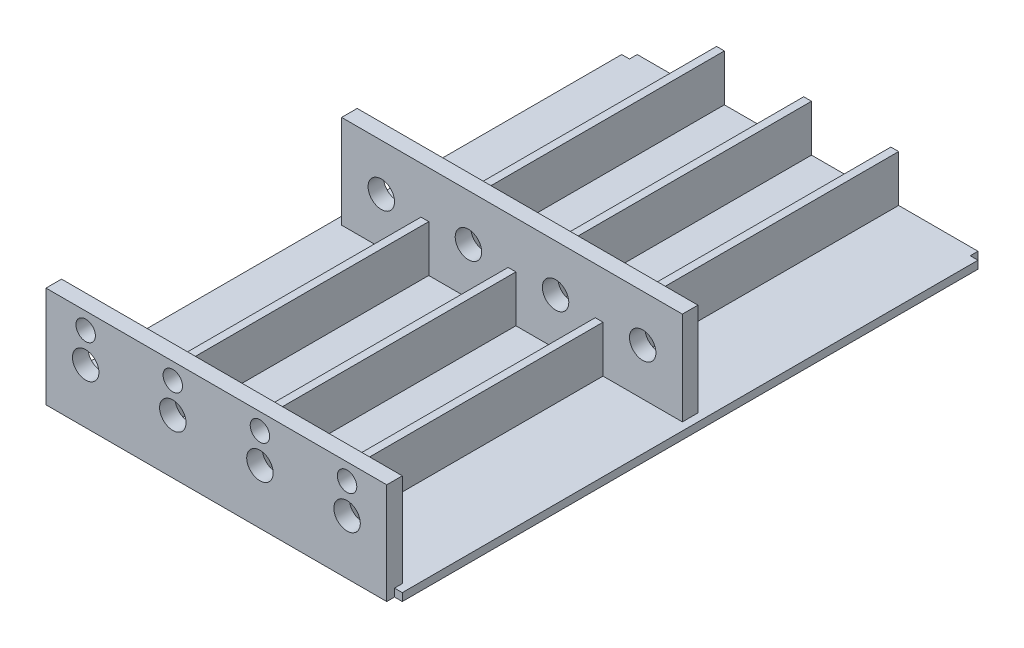
from build123d import *

# Parameters (mm, degrees)
GEARBOX_MOUNT_DEPTH = 76
BOSS_EXTRUDE6_START = 37
SKETCH7_R           = 1.7
BOSS_EXTRUDE6_DEPTH = 1
BOSS_EXTRUDE7_START = 75
SKETCH8_R           = 1.7
SKETCH8_R_2         = 1.25
BOSS_EXTRUDE7_DEPTH = 1
SKETCH9_W           = 1
SKETCH9_H           = 1
CUT_EXTRUDE1_DEPTH  = 119.118983452


with BuildPart() as part:
    # Sketch2 → Gearbox Mount (new body)
    with BuildSketch(Plane.XY):
        Polygon((-24.506477671, 76.636122542), (-24.506477671, 70.636122542), (-14.306477671, 70.636122542), (-14.306477671, 76.636122542), (-13.306477671, 76.636122542), (-13.306477671, 70.636122542), (-3.106477671, 70.636122542), (-3.106477671, 76.636122542), (-2.106477671, 76.636122542), (-2.106477671, 70.636122542), (8.093522329, 70.636122542), (9.093522329, 70.636122542), (9.093522329, 69.636122542), (-36.706477671, 69.636122542), (-36.706477671, 70.636122542), (-35.706477671, 70.636122542), (-25.506477671, 70.636122542), (-25.506477671, 76.636122542), align=None)
    extrude(amount=GEARBOX_MOUNT_DEPTH)

    # Sketch7 → Boss-Extrude6 (add, symmetric)
    with BuildSketch(Plane.XY.offset(BOSS_EXTRUDE6_START)):
        Polygon((-24.506477671, 76.636122542), (-24.506477671, 70.636122542), (-14.306477671, 70.636122542), (-14.306477671, 76.636122542), (-13.306477671, 76.636122542), (-13.306477671, 70.636122542), (-3.106477671, 70.636122542), (-3.106477671, 76.636122542), (-2.106477671, 76.636122542), (-2.106477671, 70.636122542), (8.093522329, 70.636122542), (8.093522329, 82.636122542), (-35.706477671, 82.636122542), (-35.706477671, 70.636122542), (-25.506477671, 70.636122542), (-25.506477671, 76.636122542), align=None)
        with Locations((-19.406477671, 76.636122542)):
            Circle(SKETCH7_R, mode=Mode.SUBTRACT)
        with Locations((-30.606477671, 76.636122542)):
            Circle(SKETCH7_R, mode=Mode.SUBTRACT)
        with Locations((-8.206477671, 76.636122542)):
            Circle(SKETCH7_R, mode=Mode.SUBTRACT)
        with Locations((2.993522329, 76.636122542)):
            Circle(SKETCH7_R, mode=Mode.SUBTRACT)
    extrude(amount=BOSS_EXTRUDE6_DEPTH, both=True)

    # Sketch8 → Boss-Extrude7 (add, symmetric)
    with BuildSketch(Plane.XY.offset(BOSS_EXTRUDE7_START)):
        Polygon((-35.706477671, 82.636122542), (-35.706477671, 70.636122542), (-25.506477671, 70.636122542), (-25.506477671, 76.636122542), (-24.506477671, 76.636122542), (-24.506477671, 70.636122542), (-14.306477671, 70.636122542), (-14.306477671, 76.636122542), (-13.306477671, 76.636122542), (-13.306477671, 70.636122542), (-3.106477671, 70.636122542), (-3.106477671, 76.636122542), (-2.106477671, 76.636122542), (-2.106477671, 70.636122542), (8.093522329, 70.636122542), (8.093522329, 82.636122542), align=None)
        with Locations((-30.606477671, 76.636122542)):
            Circle(SKETCH8_R, mode=Mode.SUBTRACT)
        with Locations((-30.606477671, 80.486122542)):
            Circle(SKETCH8_R_2, mode=Mode.SUBTRACT)
        with Locations((-19.406477671, 80.486122542)):
            Circle(SKETCH8_R_2, mode=Mode.SUBTRACT)
        with Locations((-19.406477671, 76.636122542)):
            Circle(SKETCH8_R, mode=Mode.SUBTRACT)
        with Locations((-8.206477671, 80.486122542)):
            Circle(SKETCH8_R_2, mode=Mode.SUBTRACT)
        with Locations((-8.206477671, 76.636122542)):
            Circle(SKETCH8_R, mode=Mode.SUBTRACT)
        with Locations((2.993522329, 80.486122542)):
            Circle(SKETCH8_R_2, mode=Mode.SUBTRACT)
        with Locations((2.993522329, 76.636122542)):
            Circle(SKETCH8_R, mode=Mode.SUBTRACT)
    extrude(amount=BOSS_EXTRUDE7_DEPTH, both=True)

    # Sketch9 → Cut-Extrude1 (cut, through all)
    with BuildSketch(Plane(origin=(0, 0, 0), x_dir=(1, 0, 0), z_dir=(0, 1, 0))):
        with Locations((-36.206477671, -0.5)):
            Rectangle(SKETCH9_W, SKETCH9_H)
        with Locations((8.593522329, -0.5)):
            Rectangle(SKETCH9_W, SKETCH9_H)
        with Locations((8.593522329, -75.5)):
            Rectangle(SKETCH9_W, SKETCH9_H)
        with Locations((-36.206477671, -75.5)):
            Rectangle(SKETCH9_W, SKETCH9_H)
    extrude(amount=CUT_EXTRUDE1_DEPTH, mode=Mode.SUBTRACT)


solid = part.part
